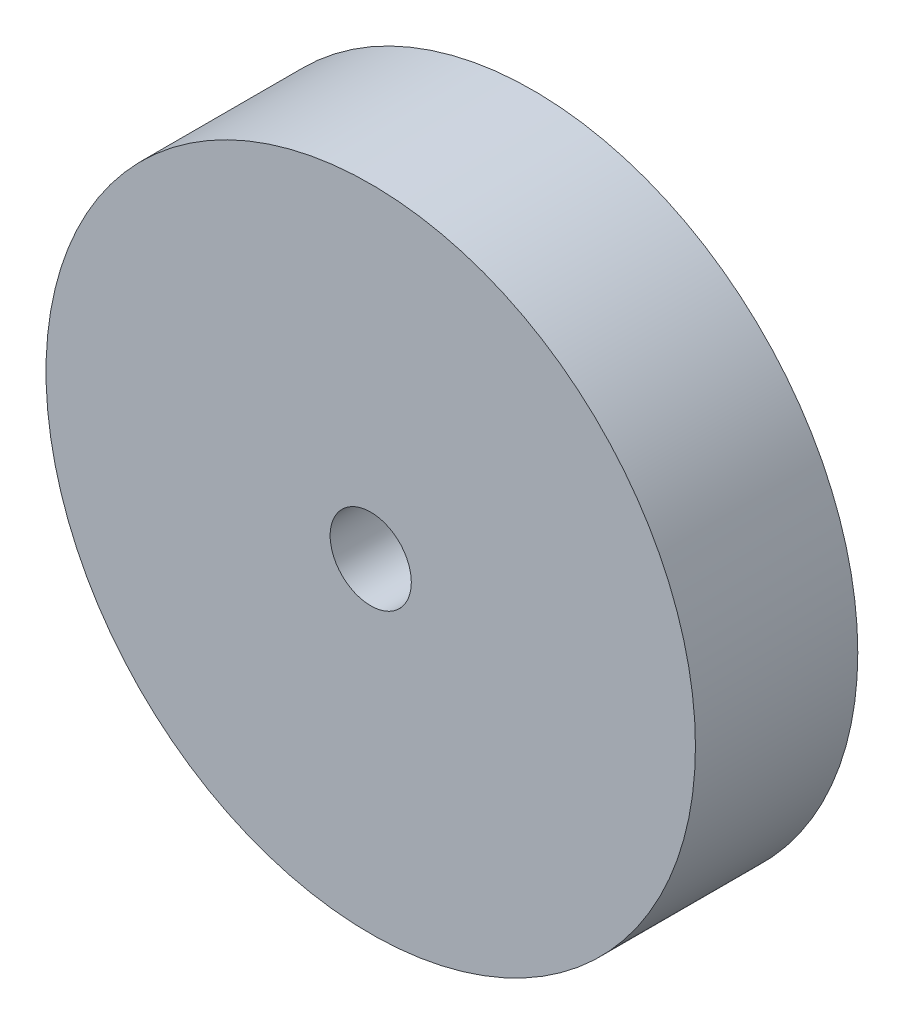
from build123d import *

# Parameters (mm, degrees)
SKETCH1_R           = 25.4
BOSS_EXTRUDE1_DEPTH = 12.7
SKETCH2_R           = 3.175
CUT_EXTRUDE1_DEPTH  = 6.35


with BuildPart() as part:
    # Sketch1 → Boss-Extrude1 (new body)
    with BuildSketch(Plane.XY):
        Circle(SKETCH1_R)
    extrude(amount=BOSS_EXTRUDE1_DEPTH)

    # Sketch2 → Cut-Extrude1 (cut)
    with BuildSketch(Plane.XY.offset(12.7)):
        Circle(SKETCH2_R)
    extrude(amount=-CUT_EXTRUDE1_DEPTH, mode=Mode.SUBTRACT)


solid = part.part
